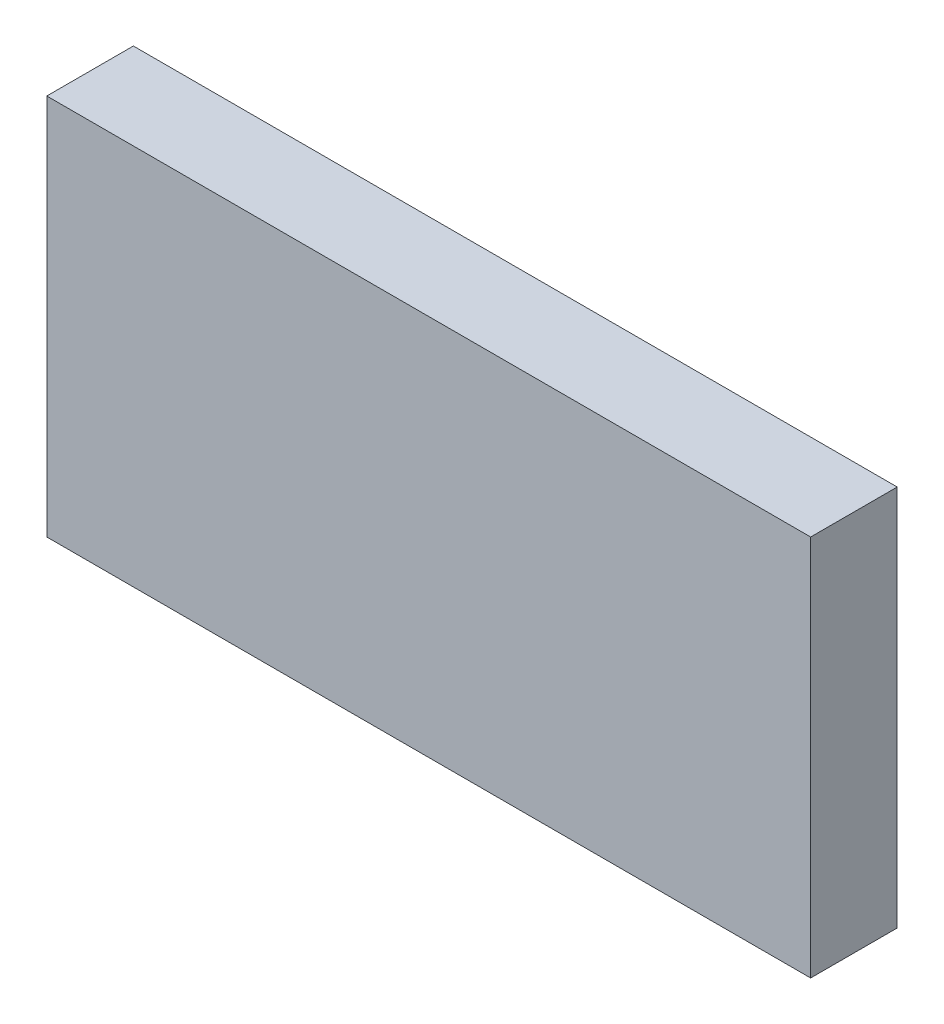
from build123d import *

# Parameters (mm, degrees)
SKETCH_1_W      = 30
SKETCH_1_H      = 15
EXTRUDE_1_DEPTH = 3.4


with BuildPart() as part:
    # ｽｹｯﾁ1 → ﾎﾞｽ - 押し出し1 (new body)
    with BuildSketch(Plane.XY):
        with Locations((15, 7.5)):
            Rectangle(SKETCH_1_W, SKETCH_1_H)
    extrude(amount=EXTRUDE_1_DEPTH)


solid = part.part
